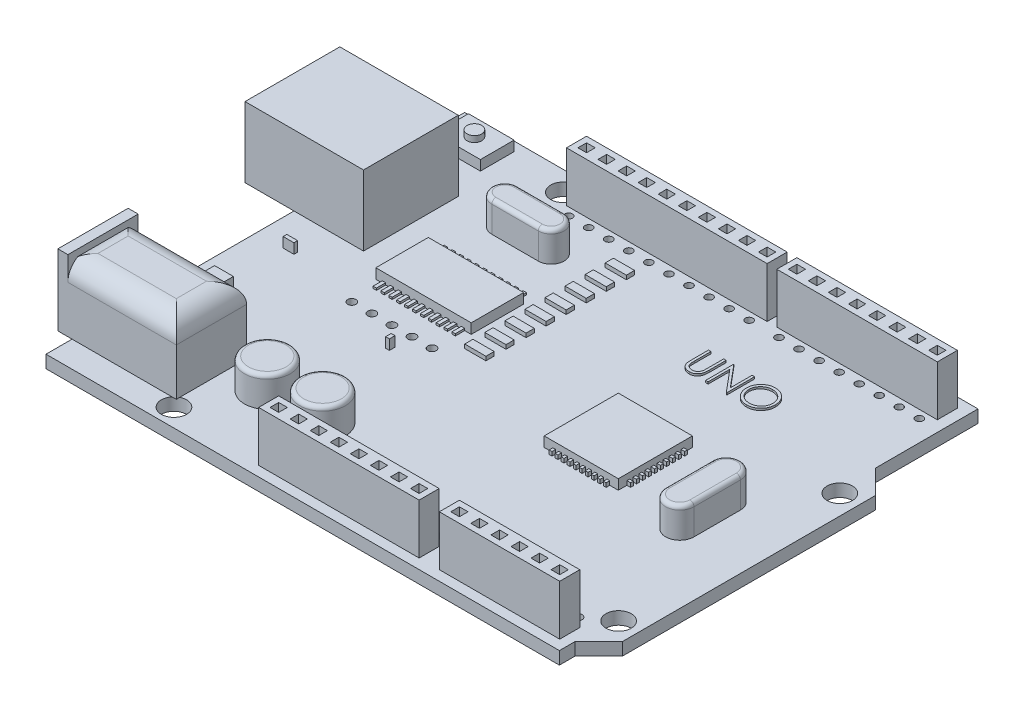
from build123d import *

# Parameters (mm, degrees)
SKETCH2_R            = 1.6
BOSS_EXTRUDE1_DEPTH  = 1.6
SKETCH3_W            = 15
SKETCH3_H            = 12
BOSS_EXTRUDE2_DEPTH  = 8.9
SKETCH5_W            = 5.784834909
SKETCH5_H            = 4.274350239
BOSS_EXTRUDE3_DEPTH  = 1.27
SKETCH6_R            = 0.927751565
BOSS_EXTRUDE4_DEPTH  = 0.762
SKETCH7_W            = 15
SKETCH7_H            = 8.9
BOSS_EXTRUDE5_DEPTH  = 8.5
FILLET1_R            = 2.54
SKETCH8_W            = 8.9
SKETCH8_H            = 9
BOSS_EXTRUDE6_DEPTH  = 1.27
SKETCH9_R            = 3
CUT_EXTRUDE2_DEPTH   = 8.89
SKETCH11_R           = 2.891497506
BOSS_EXTRUDE8_DEPTH  = 3.81
FILLET2_R            = 0.508
FILLET3_R            = 0.508
SKETCH12_W           = 25.4
SKETCH12_H           = 2.54
SKETCH12_W_2         = 20.32
SKETCH12_W_3         = 15.24
BOSS_EXTRUDE9_DEPTH  = 6.35
SKETCH13_W           = 1.092691038
SKETCH13_H           = 1.092691038
CUT_EXTRUDE3_DEPTH   = 3.81
SKETCH15_W           = 9.383454004
SKETCH15_H           = 9.383454004
SKETCH15_W_2         = 1.37077923
SKETCH15_H_2         = 0.47120536
SKETCH15_W_3         = 0.479377471
SKETCH15_H_3         = 0.70496687
SKETCH15_W_4         = 2.383958114
SKETCH15_H_4         = 3.926067116
SKETCH15_W_5         = 12.077754561
SKETCH15_H_5         = 6.642765009
BOSS_EXTRUDE10_DEPTH = 1.27
SKETCH16_R           = 1.256460162
SKETCH16_R_2         = 0.477788407
CUT_EXTRUDE5_DEPTH   = 3.81
SKETCH17_W           = 2.681446364
SKETCH17_H           = 1.042861934
BOSS_EXTRUDE11_DEPTH = 0.508
SKETCH20_R           = 0.567610843
CUT_EXTRUDE6_DEPTH   = 23.368
SKETCH21_R           = 0.528248536
CUT_EXTRUDE7_DEPTH   = 13.208
SKETCH22_W           = 0.352103619
SKETCH22_H           = 0.914597612
SKETCH22_W_2         = 0.914597611
SKETCH22_H_2         = 0.352103618
BOSS_EXTRUDE12_DEPTH = 0.508
BOSS_EXTRUDE14_DEPTH = 0.254
SKETCH25_W           = 0.425674812
SKETCH25_H           = 9
BOSS_EXTRUDE15_DEPTH = 0.254
SKETCH26_W           = 4
SKETCH26_H           = 1.5
CUT_EXTRUDE8_DEPTH   = 12


with BuildPart() as part:
    # Sketch2 → Boss-Extrude1 (new body)
    with BuildSketch(Plane(origin=(0, 0, 0), x_dir=(1, 0, 0), z_dir=(0, 1, 0))):
        Polygon((0, 0), (65, 0), (65, -13), (68, -16), (68, -48), (65, -51), (65, -53), (0, -53), align=None)
        with Locations((15, -2.5)):
            Circle(SKETCH2_R, mode=Mode.SUBTRACT)
        with Locations((65.5, -18)):
            Circle(SKETCH2_R, mode=Mode.SUBTRACT)
        with Locations((65.5, -46)):
            Circle(SKETCH2_R, mode=Mode.SUBTRACT)
        with Locations((13.9, -50.7)):
            Circle(SKETCH2_R, mode=Mode.SUBTRACT)
    extrude(amount=BOSS_EXTRUDE1_DEPTH)

    # Sketch3 → Boss-Extrude2 (add)
    with BuildSketch(Plane(origin=(0, 1.6, 0), x_dir=(1, 0, 0), z_dir=(0, 1, 0))):
        with Locations((1.3, -15.6)):
            Rectangle(SKETCH3_W, SKETCH3_H)
    extrude(amount=BOSS_EXTRUDE2_DEPTH)

    # Sketch5 → Boss-Extrude3 (add)
    with BuildSketch(Plane(origin=(0, 1.6, 0), x_dir=(1, 0, 0), z_dir=(0, 1, 0))):
        with Locations((4.535835999, -3.294296572)):
            Rectangle(SKETCH5_W, SKETCH5_H)
    extrude(amount=BOSS_EXTRUDE3_DEPTH)

    # Sketch6 → Boss-Extrude4 (add)
    with BuildSketch(Plane(origin=(0, 2.87, 0), x_dir=(1, 0, 0), z_dir=(0, 1, 0))):
        with Locations((4.535835999, -3.294296572)):
            Circle(SKETCH6_R)
    extrude(amount=BOSS_EXTRUDE4_DEPTH)

    # Sketch7 → Boss-Extrude5 (add)
    with BuildSketch(Plane(origin=(0, 1.6, 0), x_dir=(1, 0, 0), z_dir=(0, 1, 0))):
        with Locations((5.7, -45.25)):
            Rectangle(SKETCH7_W, SKETCH7_H)
    extrude(amount=BOSS_EXTRUDE5_DEPTH)

    # Fillet1
    fillet1_edges = [part.edges().sort_by_distance(p)[0] for p in [
        (13.2, 10.1, 45.25),
        (5.7, 10.1, 40.8),
        (-1.8, 10.1, 45.25),
        (5.7, 10.1, 49.7),
    ]]
    fillet(fillet1_edges, radius=FILLET1_R)

    # Sketch8 → Boss-Extrude6 (add)
    with BuildSketch(Plane.ZY.offset(1.8)):
        with Locations((45.25, 6.1)):
            Rectangle(SKETCH8_W, SKETCH8_H)
    extrude(amount=-BOSS_EXTRUDE6_DEPTH)

    # Sketch9 → Cut-Extrude2 (cut)
    with BuildSketch(Plane.ZY.offset(1.8)):
        with Locations((45.25, 6.1)):
            Circle(SKETCH9_R)
    extrude(amount=-CUT_EXTRUDE2_DEPTH, mode=Mode.SUBTRACT)

    # Sketch11 → Boss-Extrude8 (add)
    with BuildSketch(Plane(origin=(0, 1.6, 0), x_dir=(1, 0, 0), z_dir=(0, 1, 0))):
        with Locations((18.020161488, -43)):
            Circle(SKETCH11_R)
        with Locations((25.020161488, -43)):
            Circle(SKETCH11_R)
        with BuildLine():
            Line((15.082981888, -8.368233556), (20.957341088, -8.368233556))
            ThreePointArc((20.957341088, -8.368233556), (22.589107532, -10), (20.957341088, -11.631766444))
            Line((20.957341088, -11.631766444), (15.082981888, -11.631766444))
            ThreePointArc((15.082981888, -11.631766444), (13.451215444, -10), (15.082981888, -8.368233556))
        make_face()
        with BuildLine():
            Line((57.465611237, -32.012155628), (57.465611237, -26.137796429))
            ThreePointArc((57.465611237, -26.137796429), (59.260554326, -24.34285334), (61.055497414, -26.137796429))
            Line((61.055497414, -26.137796429), (61.055497414, -32.012155628))
            ThreePointArc((61.055497414, -32.012155628), (59.260554326, -33.807098717), (57.465611237, -32.012155628))
        make_face()
    extrude(amount=BOSS_EXTRUDE8_DEPTH)

    # Fillet2
    fillet2_edges = [part.edges().sort_by_distance(p)[0] for p in [
        (15.128663982, 5.41, 43),
    ]]
    fillet(fillet2_edges, radius=FILLET2_R)

    # Fillet3
    fillet3_edges = [part.edges().sort_by_distance(p)[0] for p in [
        (22.128663982, 5.41, 43),
        (13.451215444, 5.41, 10),
        (18.020161488, 5.41, 11.631766444),
        (22.589107532, 5.41, 10),
        (18.020161488, 5.41, 8.368233556),
        (59.260554326, 5.41, 33.807098717),
        (61.055497414, 5.41, 29.074976028),
        (59.260554326, 5.41, 24.34285334),
        (57.465611237, 5.41, 29.074976028),
    ]]
    fillet(fillet3_edges, radius=FILLET3_R)

    # Sketch12 → Boss-Extrude9 (add)
    with BuildSketch(Plane(origin=(0, 1.6, 0), x_dir=(1, 0, 0), z_dir=(0, 1, 0))):
        with Locations((29.37, -2.5)):
            Rectangle(SKETCH12_W, SKETCH12_H)
        with Locations((53.46, -2.5)):
            Rectangle(SKETCH12_W_2, SKETCH12_H)
        with Locations((35.81, -50.46)):
            Rectangle(SKETCH12_W_2, SKETCH12_H)
        with Locations((56.15, -50.46)):
            Rectangle(SKETCH12_W_3, SKETCH12_H)
    extrude(amount=BOSS_EXTRUDE9_DEPTH)

    # Sketch13 → Cut-Extrude3 (cut)
    with BuildSketch(Plane(origin=(0, 7.95, 0), x_dir=(1, 0, 0), z_dir=(0, 1, 0))):
        with Locations((20.48, -2.5)):
            Rectangle(SKETCH13_W, SKETCH13_H)
        with Locations((17.94, -2.5)):
            Rectangle(SKETCH13_W, SKETCH13_H)
        with Locations((23.02, -2.5)):
            Rectangle(SKETCH13_W, SKETCH13_H)
        with Locations((25.56, -2.5)):
            Rectangle(SKETCH13_W, SKETCH13_H)
        with Locations((28.1, -2.5)):
            Rectangle(SKETCH13_W, SKETCH13_H)
        with Locations((30.64, -2.5)):
            Rectangle(SKETCH13_W, SKETCH13_H)
        with Locations((33.18, -2.5)):
            Rectangle(SKETCH13_W, SKETCH13_H)
        with Locations((35.72, -2.5)):
            Rectangle(SKETCH13_W, SKETCH13_H)
        with Locations((44.57, -2.5)):
            Rectangle(SKETCH13_W, SKETCH13_H)
        with Locations((49.65, -2.5)):
            Rectangle(SKETCH13_W, SKETCH13_H)
        with Locations((52.19, -2.5)):
            Rectangle(SKETCH13_W, SKETCH13_H)
        with Locations((54.73, -2.5)):
            Rectangle(SKETCH13_W, SKETCH13_H)
        with Locations((57.27, -2.5)):
            Rectangle(SKETCH13_W, SKETCH13_H)
        with Locations((59.81, -2.5)):
            Rectangle(SKETCH13_W, SKETCH13_H)
        with Locations((62.35, -2.5)):
            Rectangle(SKETCH13_W, SKETCH13_H)
        with Locations((47.11, -2.5)):
            Rectangle(SKETCH13_W, SKETCH13_H)
        with Locations((42.16, -50.46)):
            Rectangle(SKETCH13_W, SKETCH13_H)
        with Locations((26.92, -50.46)):
            Rectangle(SKETCH13_W, SKETCH13_H)
        with Locations((29.46, -50.46)):
            Rectangle(SKETCH13_W, SKETCH13_H)
        with Locations((32, -50.46)):
            Rectangle(SKETCH13_W, SKETCH13_H)
        with Locations((34.54, -50.46)):
            Rectangle(SKETCH13_W, SKETCH13_H)
        with Locations((37.08, -50.46)):
            Rectangle(SKETCH13_W, SKETCH13_H)
        with Locations((39.62, -50.46)):
            Rectangle(SKETCH13_W, SKETCH13_H)
        with Locations((49.8, -50.46)):
            Rectangle(SKETCH13_W, SKETCH13_H)
        with Locations((54.88, -50.46)):
            Rectangle(SKETCH13_W, SKETCH13_H)
        with Locations((57.42, -50.46)):
            Rectangle(SKETCH13_W, SKETCH13_H)
        with Locations((59.96, -50.46)):
            Rectangle(SKETCH13_W, SKETCH13_H)
        with Locations((62.5, -50.46)):
            Rectangle(SKETCH13_W, SKETCH13_H)
        with Locations((52.34, -50.46)):
            Rectangle(SKETCH13_W, SKETCH13_H)
        with Locations((38.26, -2.5)):
            Rectangle(SKETCH13_W, SKETCH13_H)
        with Locations((40.8, -2.5)):
            Rectangle(SKETCH13_W, SKETCH13_H)
        with Locations((44.7, -50.46)):
            Rectangle(SKETCH13_W, SKETCH13_H)
    extrude(amount=-CUT_EXTRUDE3_DEPTH, mode=Mode.SUBTRACT)

    # Sketch15 → Boss-Extrude10 (add)
    with BuildSketch(Plane(origin=(0, 1.6, 0), x_dir=(1, 0, 0), z_dir=(0, 1, 0))):
        with Locations((46.462059645, -27)):
            Rectangle(SKETCH15_W, SKETCH15_H)
        with Locations((4.063927072, -26.122407516)):
            Rectangle(SKETCH15_W_2, SKETCH15_H_2)
        with Locations((21.088489912, -30.501033659)):
            Rectangle(SKETCH15_W_3, SKETCH15_H_3)
        with Locations((3.418816463, -35.846636428)):
            Rectangle(SKETCH15_W_4, SKETCH15_H_4)
        with Locations((18.71036712, -20.592370452)):
            Rectangle(SKETCH15_W_5, SKETCH15_H_5)
    extrude(amount=BOSS_EXTRUDE10_DEPTH)

    # Sketch16 → Cut-Extrude5 (cut)
    with BuildSketch(Plane(origin=(0, 1.6, 0), x_dir=(1, 0, 0), z_dir=(0, 1, 0))):
        with Locations((-9.905759976, 11.14826514)):
            Circle(SKETCH16_R)
        with Locations((30.64, -4.77)):
            Circle(SKETCH16_R_2)
        with Locations((33.18, -4.77)):
            Circle(SKETCH16_R_2)
        with Locations((17.94, -4.77)):
            Circle(SKETCH16_R_2)
        with Locations((20.48, -4.77)):
            Circle(SKETCH16_R_2)
        with Locations((23.02, -4.77)):
            Circle(SKETCH16_R_2)
        with Locations((25.56, -4.77)):
            Circle(SKETCH16_R_2)
        with Locations((28.1, -4.77)):
            Circle(SKETCH16_R_2)
        with Locations((35.72, -4.77)):
            Circle(SKETCH16_R_2)
        with Locations((38.26, -4.77)):
            Circle(SKETCH16_R_2)
        with Locations((40.8, -4.77)):
            Circle(SKETCH16_R_2)
        with Locations((44.57, -4.77)):
            Circle(SKETCH16_R_2)
        with Locations((47.11, -4.77)):
            Circle(SKETCH16_R_2)
        with Locations((49.65, -4.77)):
            Circle(SKETCH16_R_2)
        with Locations((57.27, -4.77)):
            Circle(SKETCH16_R_2)
        with Locations((59.81, -4.77)):
            Circle(SKETCH16_R_2)
        with Locations((62.35, -4.77)):
            Circle(SKETCH16_R_2)
        with Locations((52.19, -4.77)):
            Circle(SKETCH16_R_2)
        with Locations((54.73, -4.77)):
            Circle(SKETCH16_R_2)
    extrude(amount=-CUT_EXTRUDE5_DEPTH, mode=Mode.SUBTRACT)

    # Sketch17 → Boss-Extrude11 (add)
    with BuildSketch(Plane(origin=(0, 1.6, 0), x_dir=(1, 0, 0), z_dir=(0, 1, 0))):
        with Locations((27.24163698, -25.362955729)):
            Rectangle(SKETCH17_W, SKETCH17_H)
        with Locations((27.24163698, -22.822955729)):
            Rectangle(SKETCH17_W, SKETCH17_H)
        with Locations((27.24163698, -20.282955729)):
            Rectangle(SKETCH17_W, SKETCH17_H)
        with Locations((27.24163698, -17.742955729)):
            Rectangle(SKETCH17_W, SKETCH17_H)
        with Locations((27.24163698, -15.202955729)):
            Rectangle(SKETCH17_W, SKETCH17_H)
        with Locations((27.24163698, -12.662955729)):
            Rectangle(SKETCH17_W, SKETCH17_H)
        with Locations((27.24163698, -10.122955729)):
            Rectangle(SKETCH17_W, SKETCH17_H)
        with Locations((27.24163698, -7.582955729)):
            Rectangle(SKETCH17_W, SKETCH17_H)
    extrude(amount=BOSS_EXTRUDE11_DEPTH)

    # Sketch20 → Cut-Extrude6 (cut)
    with BuildSketch(Plane(origin=(0, 1.6, 0), x_dir=(1, 0, 0), z_dir=(0, 1, 0))):
        with Locations((26.92, -48.19)):
            Circle(SKETCH20_R)
        with Locations((29.46, -48.19)):
            Circle(SKETCH20_R)
        with Locations((32, -48.19)):
            Circle(SKETCH20_R)
        with Locations((34.54, -48.19)):
            Circle(SKETCH20_R)
        with Locations((37.08, -48.19)):
            Circle(SKETCH20_R)
        with Locations((39.62, -48.19)):
            Circle(SKETCH20_R)
        with Locations((42.16, -48.19)):
            Circle(SKETCH20_R)
        with Locations((44.7, -48.19)):
            Circle(SKETCH20_R)
        with Locations((49.8, -48.19)):
            Circle(SKETCH20_R)
        with Locations((52.34, -48.19)):
            Circle(SKETCH20_R)
        with Locations((54.88, -48.19)):
            Circle(SKETCH20_R)
        with Locations((57.42, -48.19)):
            Circle(SKETCH20_R)
        with Locations((59.96, -48.19)):
            Circle(SKETCH20_R)
        with Locations((62.5, -48.19)):
            Circle(SKETCH20_R)
    extrude(amount=-CUT_EXTRUDE6_DEPTH, mode=Mode.SUBTRACT)

    # Sketch21 → Cut-Extrude7 (cut)
    with BuildSketch(Plane(origin=(0, 1.6, 0), x_dir=(1, 0, 0), z_dir=(0, 1, 0))):
        with Locations((13.630367119, -27.913752956)):
            Circle(SKETCH21_R)
        with Locations((16.170367119, -27.913752956)):
            Circle(SKETCH21_R)
        with Locations((18.710367119, -27.913752956)):
            Circle(SKETCH21_R)
        with Locations((21.250367119, -27.913752956)):
            Circle(SKETCH21_R)
        with Locations((23.790367119, -27.913752956)):
            Circle(SKETCH21_R)
    extrude(amount=-CUT_EXTRUDE7_DEPTH, mode=Mode.SUBTRACT)

    # Sketch22 → Boss-Extrude12 (add)
    with BuildSketch(Plane(origin=(0, 1.6, 0), x_dir=(1, 0, 0), z_dir=(0, 1, 0))):
        with Locations((43.033059644, -31.691727002)):
            Rectangle(SKETCH22_W, SKETCH22_H)
        with Locations((43.795059645, -31.691727002)):
            Rectangle(SKETCH22_W, SKETCH22_H)
        with Locations((44.557059645, -31.691727002)):
            Rectangle(SKETCH22_W, SKETCH22_H)
        with Locations((45.319059645, -31.691727002)):
            Rectangle(SKETCH22_W, SKETCH22_H)
        with Locations((46.081059645, -31.691727002)):
            Rectangle(SKETCH22_W, SKETCH22_H)
        with Locations((46.843059645, -31.691727002)):
            Rectangle(SKETCH22_W, SKETCH22_H)
        with Locations((47.605059645, -31.691727002)):
            Rectangle(SKETCH22_W, SKETCH22_H)
        with Locations((48.367059645, -31.691727002)):
            Rectangle(SKETCH22_W, SKETCH22_H)
        with Locations((49.129059645, -31.691727002)):
            Rectangle(SKETCH22_W, SKETCH22_H)
        with Locations((49.891059645, -31.691727002)):
            Rectangle(SKETCH22_W, SKETCH22_H)
        with Locations((41.770332643, -23.571)):
            Rectangle(SKETCH22_W_2, SKETCH22_H_2)
        with Locations((41.770332643, -24.333)):
            Rectangle(SKETCH22_W_2, SKETCH22_H_2)
        with Locations((41.770332643, -25.095)):
            Rectangle(SKETCH22_W_2, SKETCH22_H_2)
        with Locations((41.770332643, -25.857)):
            Rectangle(SKETCH22_W_2, SKETCH22_H_2)
        with Locations((41.770332643, -26.619)):
            Rectangle(SKETCH22_W_2, SKETCH22_H_2)
        with Locations((41.770332643, -27.381)):
            Rectangle(SKETCH22_W_2, SKETCH22_H_2)
        with Locations((41.770332643, -28.143)):
            Rectangle(SKETCH22_W_2, SKETCH22_H_2)
        with Locations((41.770332643, -28.905)):
            Rectangle(SKETCH22_W_2, SKETCH22_H_2)
        with Locations((41.770332643, -29.667)):
            Rectangle(SKETCH22_W_2, SKETCH22_H_2)
        with Locations((41.770332643, -30.429)):
            Rectangle(SKETCH22_W_2, SKETCH22_H_2)
        with Locations((49.891059645, -22.308272998)):
            Rectangle(SKETCH22_W, SKETCH22_H)
        with Locations((49.129059645, -22.308272998)):
            Rectangle(SKETCH22_W, SKETCH22_H)
        with Locations((48.367059645, -22.308272998)):
            Rectangle(SKETCH22_W, SKETCH22_H)
        with Locations((47.605059645, -22.308272998)):
            Rectangle(SKETCH22_W, SKETCH22_H)
        with Locations((46.843059645, -22.308272998)):
            Rectangle(SKETCH22_W, SKETCH22_H)
        with Locations((46.081059645, -22.308272998)):
            Rectangle(SKETCH22_W, SKETCH22_H)
        with Locations((45.319059645, -22.308272998)):
            Rectangle(SKETCH22_W, SKETCH22_H)
        with Locations((44.557059645, -22.308272998)):
            Rectangle(SKETCH22_W, SKETCH22_H)
        with Locations((43.795059645, -22.308272998)):
            Rectangle(SKETCH22_W, SKETCH22_H)
        with Locations((43.033059644, -22.308272998)):
            Rectangle(SKETCH22_W, SKETCH22_H)
        with Locations((51.153786647, -30.429)):
            Rectangle(SKETCH22_W_2, SKETCH22_H_2)
        with Locations((51.153786647, -29.667)):
            Rectangle(SKETCH22_W_2, SKETCH22_H_2)
        with Locations((51.153786647, -28.905)):
            Rectangle(SKETCH22_W_2, SKETCH22_H_2)
        with Locations((51.153786647, -28.143)):
            Rectangle(SKETCH22_W_2, SKETCH22_H_2)
        with Locations((51.153786647, -27.381)):
            Rectangle(SKETCH22_W_2, SKETCH22_H_2)
        with Locations((51.153786647, -26.619)):
            Rectangle(SKETCH22_W_2, SKETCH22_H_2)
        with Locations((51.153786647, -25.857)):
            Rectangle(SKETCH22_W_2, SKETCH22_H_2)
        with Locations((51.153786647, -25.095)):
            Rectangle(SKETCH22_W_2, SKETCH22_H_2)
        with Locations((51.153786647, -24.333)):
            Rectangle(SKETCH22_W_2, SKETCH22_H_2)
        with Locations((51.153786647, -23.571)):
            Rectangle(SKETCH22_W_2, SKETCH22_H_2)
    extrude(amount=BOSS_EXTRUDE12_DEPTH)

    # Sketch18 → Boss-Extrude14 (add)
    with BuildSketch(Plane(origin=(0, 1.6, 0), x_dir=(1, 0, 0), z_dir=(0, 1, 0))):
        with BuildLine():
            Line((41.744551722, -10.867740388), (42.058654286, -10.867740388))
            Line((42.058654286, -10.867740388), (42.058654286, -12.964795677))
            add(Edge.make_bspline(
                [(42.058654286, -12.964795677), (42.058607542, -12.994476412), (42.058518838, -13.050800723), (42.059111352, -13.130969024), (42.06077072, -13.202241483), (42.06181688, -13.26489283), (42.064144213, -13.318635578), (42.06604226, -13.363760889), (42.068482817, -13.400055091), (42.071415934, -13.421236017), (42.072676722, -13.430340548)],
                knots=[0, 0, 0, 0, 8.9042e-05, 0.000168973, 0.000240502, 0.000302917, 0.000356945, 0.000401866, 0.000438432, 0.000465999, 0.000465999, 0.000465999, 0.000465999], degree=3))
            add(Edge.make_bspline(
                [(42.072676722, -13.430340548), (42.077854181, -13.463187312), (42.087917367, -13.527030041), (42.113563745, -13.617938323), (42.149381246, -13.699869781), (42.191824289, -13.775381072), (42.2477569, -13.842370432), (42.314760436, -13.904082085), (42.395938204, -13.95805389), (42.48619881, -14.007404701), (42.583484047, -14.047069784), (42.682895314, -14.077063148), (42.782938293, -14.095342048), (42.849914458, -14.097458587), (42.883173517, -14.098509619)],
                knots=[0, 0, 0, 0, 9.971e-05, 0.000193801, 0.000282365, 0.000367504, 0.000452699, 0.000543015, 0.000639862, 0.000744331, 0.000851226, 0.000954377, 0.001055468, 0.001155185, 0.001155185, 0.001155185, 0.001155185], degree=3))
            add(Edge.make_bspline(
                [(42.883173517, -14.098509619), (42.911727258, -14.097435769), (42.968669819, -14.09529427), (43.05327625, -14.082032839), (43.135676359, -14.058132274), (43.216277039, -14.027292515), (43.291828023, -13.986544924), (43.362371465, -13.939474085), (43.425335399, -13.884263209), (43.482793397, -13.823162864), (43.532828333, -13.754223064), (43.576199475, -13.678944926), (43.611725404, -13.596195579), (43.629268929, -13.538041157), (43.63828169, -13.508165068)],
                knots=[0, 0, 0, 0, 8.5678e-05, 0.00017086, 0.000256092, 0.000342674, 0.000429242, 0.000513055, 0.000596556, 0.000679898, 0.000764179, 0.00085149, 0.000940054, 0.001033621, 0.001033621, 0.001033621, 0.001033621], degree=3))
            add(Edge.make_bspline(
                [(43.63828169, -13.508165068), (43.641281816, -13.495816493), (43.647967304, -13.468298893), (43.654214349, -13.421777603), (43.660720874, -13.366888239), (43.665235444, -13.303236426), (43.669636665, -13.231035453), (43.672269737, -13.149909196), (43.67348677, -13.060152235), (43.673849451, -12.997515073), (43.674038902, -12.964795677)],
                knots=[0, 0, 0, 0, 3.81e-05, 8.4902e-05, 0.000140649, 0.000203941, 0.000276279, 0.000357657, 0.000447412, 0.000545571, 0.000545571, 0.000545571, 0.000545571], degree=3))
            Line((43.674038902, -12.964795677), (43.674038902, -10.867740388))
            Line((43.674038902, -10.867740388), (43.988141466, -10.867740388))
            Line((43.988141466, -10.867740388), (43.988141466, -12.9816226))
            add(Edge.make_bspline(
                [(43.988141466, -12.9816226), (43.987887345, -13.019720979), (43.987391414, -13.094072281), (43.983090838, -13.20302364), (43.976233838, -13.306376622), (43.96654575, -13.404145118), (43.953708747, -13.495979278), (43.939433526, -13.582684046), (43.921253993, -13.663637038), (43.900020592, -13.739469456), (43.875747044, -13.811654969), (43.844305895, -13.880163584), (43.808881396, -13.947077984), (43.766866743, -14.011386093), (43.71965536, -14.073372646), (43.666203679, -14.132661721), (43.608279518, -14.190200767), (43.544919959, -14.244513833), (43.477169434, -14.29432251), (43.405229476, -14.338120281), (43.329652706, -14.375143899), (43.25063558, -14.405619823), (43.168144377, -14.428534422), (43.082177017, -14.445609578), (42.992537824, -14.455311876), (42.931573168, -14.456753806), (42.900701562, -14.457483978)],
                knots=[0, 0, 0, 0, 0.000114291, 0.000223047, 0.000327049, 0.000424998, 0.000517708, 0.000605194, 0.000688542, 0.000766455, 0.0008414, 0.000916717, 0.000992315, 0.001068354, 0.001146882, 0.001225836, 0.001307639, 0.001391671, 0.001475952, 0.001559641, 0.001643989, 0.001728103, 0.001813335, 0.001900511, 0.00199079, 0.002083404, 0.002083404, 0.002083404, 0.002083404], degree=3))
            add(Edge.make_bspline(
                [(42.900701562, -14.457483978), (42.867032459, -14.456699213), (42.800973801, -14.455159506), (42.703635733, -14.446336756), (42.610321537, -14.429718361), (42.52004566, -14.408558418), (42.434037163, -14.37937468), (42.351143718, -14.345276556), (42.272785037, -14.303399295), (42.197689909, -14.256805902), (42.127865153, -14.204381264), (42.063767749, -14.14724109), (42.005291879, -14.086300713), (41.953423182, -14.020900347), (41.907302298, -13.95154864), (41.867572084, -13.8780494), (41.83345884, -13.800431084), (41.815852273, -13.746477884), (41.806951562, -13.719202728)],
                knots=[0, 0, 0, 0, 0.000101022, 0.000198206, 0.000292839, 0.000385177, 0.00047608, 0.000565014, 0.000653769, 0.000742283, 0.000829923, 0.000915339, 0.000999643, 0.001082971, 0.00116542, 0.001249186, 0.001333332, 0.001419362, 0.001419362, 0.001419362, 0.001419362], degree=3))
            add(Edge.make_bspline(
                [(41.806951562, -13.719202728), (41.801774404, -13.700570153), (41.790545032, -13.660155684), (41.778519735, -13.593269196), (41.768410653, -13.516254278), (41.758905095, -13.42910566), (41.753296137, -13.331755793), (41.748378698, -13.224246877), (41.74451708, -13.106448916), (41.744539852, -13.0243944), (41.744551722, -12.9816226)],
                knots=[0, 0, 0, 0, 5.799e-05, 0.000125782, 0.000203619, 0.000291034, 0.000388694, 0.000496078, 0.000613919, 0.000742226, 0.000742226, 0.000742226, 0.000742226], degree=3))
            Line((41.744551722, -12.9816226), (41.744551722, -10.867740388))
        make_face()
        Polygon((44.885577363, -14.367740388), (44.885577363, -10.867740388), (44.951482812, -10.867740388), (47.263782492, -13.62244792), (47.263782492, -10.867740388), (47.577885056, -10.867740388), (47.577885056, -14.367740388), (47.506370633, -14.367740388), (45.199679927, -11.619342952), (45.199679927, -14.367740388), align=None)
        with BuildLine():
            add(Edge.make_bspline(
                [(50.113141466, -10.777996798), (50.177949572, -10.779638278), (50.305238039, -10.782862279), (50.492312936, -10.807541382), (50.670908032, -10.850236772), (50.842478171, -10.907099755), (51.004971147, -10.98295414), (51.15961004, -11.074639288), (51.306026913, -11.183115747), (51.442248295, -11.307544974), (51.566905245, -11.442928428), (51.676731132, -11.587406338), (51.768773425, -11.74010514), (51.844359212, -11.900565971), (51.903657822, -12.068425939), (51.944576866, -12.244579942), (51.970715016, -12.427886632), (51.973770793, -12.552913496), (51.975320953, -12.616338144)],
                knots=[0, 0, 0, 0, 0.000194393, 0.000381804, 0.00056479, 0.000744601, 0.000923091, 0.001101652, 0.001283106, 0.001468738, 0.001654324, 0.001834514, 0.002012231, 0.002188181, 0.002365797, 0.002545211, 0.002729936, 0.002920126, 0.002920126, 0.002920126, 0.002920126], degree=3))
            add(Edge.make_bspline(
                [(51.975320953, -12.616338144), (51.973771021, -12.679295591), (51.970715924, -12.803392011), (51.944547146, -12.985535455), (51.903506146, -13.160626152), (51.84490988, -13.328371805), (51.769684402, -13.488949368), (51.677029231, -13.641936322), (51.56788802, -13.787382821), (51.443681169, -13.923695486), (51.308280127, -14.048692957), (51.16304986, -14.157611832), (51.01125654, -14.251335957), (50.850946832, -14.326119631), (50.684246795, -14.385891551), (50.509664472, -14.426644181), (50.328017918, -14.452931225), (50.204146914, -14.455949741), (50.141186338, -14.457483978)],
                knots=[0, 0, 0, 0, 0.000188789, 0.000372126, 0.000550857, 0.00072758, 0.000904164, 0.001081881, 0.001263191, 0.001448823, 0.00163441, 0.001815159, 0.001992641, 0.002168591, 0.002344885, 0.002522934, 0.002705576, 0.002894365, 0.002894365, 0.002894365, 0.002894365], degree=3))
            add(Edge.make_bspline(
                [(50.141186338, -14.457483978), (50.077762019, -14.455934591), (49.952735803, -14.452880337), (49.769198767, -14.426698932), (49.592921024, -14.385757628), (49.424406672, -14.327248192), (49.263561743, -14.251630961), (49.11007166, -14.159426582), (48.964552513, -14.050019441), (48.828210766, -13.925852867), (48.703461568, -13.790681315), (48.594702192, -13.64584706), (48.502477079, -13.494191603), (48.427113747, -13.335294079), (48.367449287, -13.169922636), (48.326744469, -12.996974159), (48.300408517, -12.817434653), (48.297373671, -12.695191754), (48.295833774, -12.633165068)],
                knots=[0, 0, 0, 0, 0.00019019, 0.000374915, 0.000555011, 0.000732396, 0.00090898, 0.001087298, 0.001268608, 0.00145424, 0.001639827, 0.001819595, 0.001996712, 0.002171394, 0.002346367, 0.002523053, 0.002703612, 0.002889599, 0.002889599, 0.002889599, 0.002889599], degree=3))
            add(Edge.make_bspline(
                [(48.295833774, -12.633165068), (48.296368409, -12.591532398), (48.297430935, -12.508792275), (48.310222628, -12.385925675), (48.328784329, -12.265035017), (48.355386242, -12.146464069), (48.390177909, -12.030503084), (48.431229936, -11.916352321), (48.481369781, -11.805168598), (48.538050429, -11.696425206), (48.601312237, -11.5918173), (48.671187987, -11.492937717), (48.745223355, -11.39895672), (48.826386749, -11.312309716), (48.912003194, -11.23047606), (49.003461572, -11.154713343), (49.100203817, -11.084338392), (49.202646196, -11.020918051), (49.308264471, -10.963558916), (49.417141249, -10.914337065), (49.527797821, -10.872091004), (49.640752469, -10.837850179), (49.755705241, -10.810818143), (49.872907025, -10.792410789), (49.992264451, -10.779586471), (50.07267577, -10.778528969), (50.113141466, -10.777996798)],
                knots=[0, 0, 0, 0, 0.000124849, 0.000248123, 0.000370193, 0.00049164, 0.000612319, 0.000733199, 0.000855287, 0.000977905, 0.001100913, 0.001221706, 0.001340948, 0.001459521, 0.001577551, 0.001696047, 0.001815534, 0.001936153, 0.002057243, 0.002175846, 0.002294342, 0.002412335, 0.002529682, 0.00264829, 0.002768075, 0.00288942, 0.00288942, 0.00288942, 0.00288942], degree=3))
        make_face()
        with BuildLine():
            add(Edge.make_bspline(
                [(50.128566145, -11.136971157), (50.095351512, -11.137376048), (50.029239779, -11.138181957), (49.930955243, -11.148797673), (49.833963309, -11.163927562), (49.738243947, -11.185509083), (49.644197657, -11.214913135), (49.550947816, -11.248754044), (49.459344762, -11.289975134), (49.369690904, -11.336547839), (49.282775829, -11.388096759), (49.200763128, -11.445068526), (49.123440484, -11.506127081), (49.050997217, -11.571414918), (48.983646045, -11.64126452), (48.920061344, -11.714616956), (48.862791762, -11.793568847), (48.810306185, -11.875979254), (48.763338345, -11.961740835), (48.72157299, -12.049950697), (48.687408981, -12.141328384), (48.659546605, -12.234882542), (48.636446794, -12.330465001), (48.62181287, -12.42880085), (48.611080511, -12.529395962), (48.610320665, -12.597377816), (48.609936338, -12.631762824)],
                knots=[0, 0, 0, 0, 9.9599e-05, 0.000198245, 0.000296222, 0.00039402, 0.00049227, 0.000591646, 0.000691452, 0.000793368, 0.000894612, 0.000994383, 0.001092713, 0.00119001, 0.001286696, 0.001383657, 0.001480979, 0.001579008, 0.001676595, 0.001774142, 0.001871547, 0.001968922, 0.002066879, 0.00216624, 0.00226698, 0.002370083, 0.002370083, 0.002370083, 0.002370083], degree=3))
            add(Edge.make_bspline(
                [(48.609936338, -12.631762824), (48.6112112, -12.682325045), (48.613719247, -12.781796575), (48.635676818, -12.927564719), (48.669498792, -13.067653005), (48.719356158, -13.201294915), (48.781706773, -13.329639197), (48.858733663, -13.451547302), (48.949992749, -13.567052176), (49.053656276, -13.675347445), (49.166978982, -13.77419325), (49.287311712, -13.860956658), (49.41336532, -13.934366908), (49.545468522, -13.99417198), (49.682916061, -14.041561718), (49.826593612, -14.074040349), (49.975544072, -14.095415805), (50.077074727, -14.097468561), (50.128566145, -14.098509619)],
                knots=[0, 0, 0, 0, 0.000151605, 0.000298253, 0.000441263, 0.000583229, 0.000725274, 0.000868635, 0.001014928, 0.001166177, 0.001317744, 0.00146543, 0.001610576, 0.001754594, 0.001899821, 0.002045914, 0.002195936, 0.002350312, 0.002350312, 0.002350312, 0.002350312], degree=3))
            add(Edge.make_bspline(
                [(50.128566145, -14.098509619), (50.163175647, -14.098034114), (50.231816683, -14.097091047), (50.333912206, -14.08759237), (50.434168417, -14.0723605), (50.532444697, -14.050429845), (50.628629509, -14.022982638), (50.723124312, -13.99037491), (50.814922602, -13.949693707), (50.90518244, -13.904745755), (50.991578682, -13.853505597), (51.074054214, -13.798467448), (51.150530194, -13.737498827), (51.222919265, -13.673181015), (51.290546954, -13.604217167), (51.352955938, -13.530696945), (51.409936071, -13.452156288), (51.462401717, -13.369870882), (51.50920498, -13.283874629), (51.549984079, -13.195344951), (51.584580195, -13.104499842), (51.6125087, -13.01120827), (51.634394161, -12.915647422), (51.649474081, -12.817689343), (51.66002252, -12.717530001), (51.660817597, -12.649786145), (51.661218389, -12.615637023)],
                knots=[0, 0, 0, 0, 0.000103804, 0.000205874, 0.000307314, 0.000407849, 0.000507719, 0.000607281, 0.000707445, 0.000808723, 0.000909609, 0.001008589, 0.001105934, 0.001202762, 0.001298946, 0.001395452, 0.001491794, 0.001589823, 0.001688026, 0.001785277, 0.001882027, 0.001979402, 0.0020772, 0.002175869, 0.002276609, 0.002379011, 0.002379011, 0.002379011, 0.002379011], degree=3))
            add(Edge.make_bspline(
                [(51.661218389, -12.615637023), (51.660817276, -12.581721518), (51.660021594, -12.514443868), (51.64947912, -12.41498305), (51.634378229, -12.317729838), (51.612615521, -12.223066035), (51.584565368, -12.13096751), (51.549978037, -12.041520763), (51.509192738, -11.954392568), (51.462384513, -11.869798271), (51.40976869, -11.788623533), (51.352274447, -11.71102112), (51.288909099, -11.638448379), (51.221483074, -11.569113685), (51.148312188, -11.504495795), (51.069727894, -11.444573274), (50.986684216, -11.3879), (50.898756981, -11.336774438), (50.808013027, -11.289560206), (50.714899069, -11.249109202), (50.62046997, -11.214737083), (50.524965857, -11.185420118), (50.427582879, -11.164012088), (50.32897905, -11.148784038), (50.229290792, -11.138185652), (50.162247572, -11.137377274), (50.128566145, -11.136971157)],
                knots=[0, 0, 0, 0, 0.000101701, 0.000201743, 0.00029972, 0.000396835, 0.000492868, 0.000588308, 0.000684288, 0.000781261, 0.000878109, 0.000974304, 0.001070733, 0.001166917, 0.001264269, 0.001363274, 0.001463228, 0.001565678, 0.001668217, 0.001769947, 0.001869982, 0.001969573, 0.002069423, 0.002168785, 0.002268827, 0.002369827, 0.002369827, 0.002369827, 0.002369827], degree=3))
        make_face(mode=Mode.SUBTRACT)
    extrude(amount=BOSS_EXTRUDE14_DEPTH)

    # Sketch25 → Boss-Extrude15 (add)
    with BuildSketch(Plane(origin=(0, 1.6, 0), x_dir=(1, 0, 0), z_dir=(0, 1, 0))):
        with Locations((14.710367119, -20.592370451)):
            Rectangle(SKETCH25_W, SKETCH25_H)
        with Locations((13.710367119, -20.592370451)):
            Rectangle(SKETCH25_W, SKETCH25_H)
        with Locations((15.710367119, -20.592370451)):
            Rectangle(SKETCH25_W, SKETCH25_H)
        with Locations((16.710367119, -20.592370451)):
            Rectangle(SKETCH25_W, SKETCH25_H)
        with Locations((17.710367119, -20.592370451)):
            Rectangle(SKETCH25_W, SKETCH25_H)
        with Locations((18.710367119, -20.592370451)):
            Rectangle(SKETCH25_W, SKETCH25_H)
        with Locations((19.710367119, -20.592370451)):
            Rectangle(SKETCH25_W, SKETCH25_H)
        with Locations((20.710367119, -20.592370451)):
            Rectangle(SKETCH25_W, SKETCH25_H)
        with Locations((21.710367119, -20.592370451)):
            Rectangle(SKETCH25_W, SKETCH25_H)
        with Locations((22.710367119, -20.592370451)):
            Rectangle(SKETCH25_W, SKETCH25_H)
        with Locations((23.710367119, -20.592370451)):
            Rectangle(SKETCH25_W, SKETCH25_H)
    extrude(amount=BOSS_EXTRUDE15_DEPTH)

    # Sketch26 → Cut-Extrude8 (cut)
    with BuildSketch(Plane.ZY.offset(6.2)):
        Polygon((10.6, 2.6), (10.6, 7.5), (12.6, 9.5), (18.6, 9.5), (20.6, 7.5), (20.6, 2.6), align=None)
        with Locations((15.6, 5.75)):
            Rectangle(SKETCH26_W, SKETCH26_H, mode=Mode.SUBTRACT)
    extrude(amount=-CUT_EXTRUDE8_DEPTH, mode=Mode.SUBTRACT)


solid = part.part
